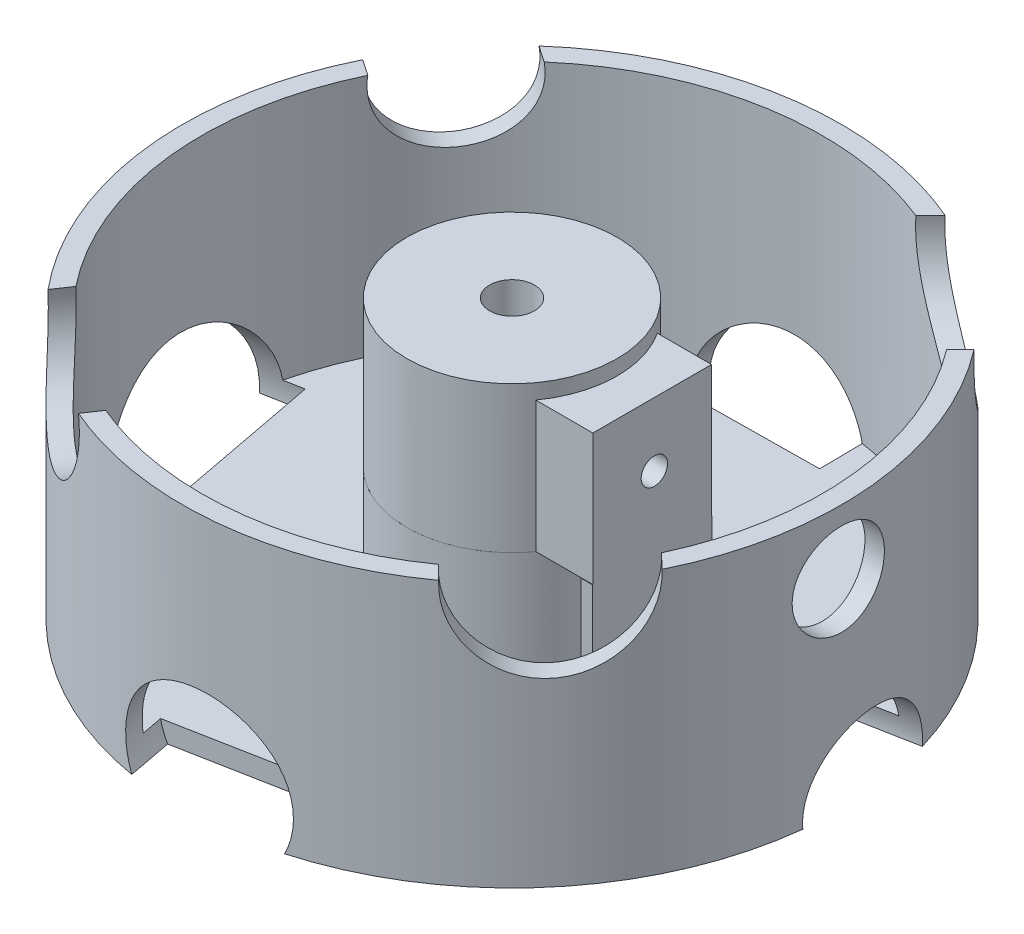
from build123d import *

# Parameters (mm, degrees)
SKETCH1_R                      = 15.958
SHAFTHOLDERNEARMOTOR_DEPTH     = 22.19
SKETCH2_R                      = 3.4
CUT_EXTRUDE1_DEPTH             = 14.35
SKETCH5_W                      = 1.550685087
SKETCH5_H                      = 7.184215806
BOSS_EXTRUDE2_DEPTH            = 13.55
SKETCH7_W                      = 18.003976239
SKETCH7_H                      = 19.909960041
BOSS_EXTRUDE3_DEPTH            = 19
SKETCH6_R                      = 2
CUT_EXTRUDE2_DEPTH             = 1
CUT_EXTRUDE2_DEPTH_BACK        = 19
SKETCH9_W                      = 7.520011657
SKETCH9_H                      = 9.493348351
NUTOPENING_DEPTH               = 30
SKETCH10_R                     = 50
BOSS_EXTRUDE4_DEPTH            = 20
SKETCH12_R                     = 47.082764373
SKETCH12_R_2                   = 15.95790089
CUTTOREMVEEXCESSMATERIAL_DEPTH = 17
SKETCH13_R                     = 50
SKETCH13_R_2                   = 47.082764373
BOSS_EXTRUDE5_DEPTH            = 20
CUT_EXTRUDE6_DEPTH             = 7.520012
SKETCH16_R                     = 7
CUT_EXTRUDE7_DEPTH             = 40
SKETCH19_R                     = 12
CUT_EXTRUDE8_DEPTH             = 10
SKETCH20_R                     = 12
CUT_EXTRUDE9_DEPTH             = 10
SKETCH22_R                     = 12.553525499
CUT_EXTRUDE10_DEPTH            = 10
SKETCH21_R                     = 10
CUT_EXTRUDE11_DEPTH            = 10
SKETCH23_R                     = 11.965333231
CUT_EXTRUDE12_DEPTH            = 10
SKETCH25_R                     = 9.629681042
CUT_EXTRUDE13_DEPTH            = 10
SKETCH26_R                     = 15.012411299
CUT_EXTRUDE14_DEPTH            = 10
SKETCH27_R                     = 11.854712092
CUT_EXTRUDE15_DEPTH            = 10
SKETCH28_W                     = 1.716796753
SKETCH28_H                     = 18.172415452
BOSS_EXTRUDE6_DEPTH            = 17


with BuildPart() as part:
    # Sketch1 → ShaftHolderNearMotor (new body)
    with BuildSketch(Plane(origin=(0, 0, 0), x_dir=(1, 0, 0), z_dir=(0, 1, 0))):
        Circle(SKETCH1_R)
    extrude(amount=SHAFTHOLDERNEARMOTOR_DEPTH)

    # Sketch2 → Cut-Extrude1 (cut)
    with BuildSketch(Plane(origin=(0, 22.19, 0), x_dir=(1, 0, 0), z_dir=(0, 1, 0))):
        Circle(SKETCH2_R)
    extrude(amount=-CUT_EXTRUDE1_DEPTH, mode=Mode.SUBTRACT)

    # Sketch5 → Boss-Extrude2 (add)
    with BuildSketch(Plane(origin=(0, 19.65, 0), x_dir=(1, 0, 0), z_dir=(0, 1, 0))):
        with Locations((3.375342544, 0.020519704)):
            Rectangle(SKETCH5_W, SKETCH5_H)
    extrude(amount=-BOSS_EXTRUDE2_DEPTH)

    # Sketch7 → Boss-Extrude3 (add)
    with BuildSketch(Plane.ZY.offset(-2.6)):
        with Locations((0.33027221, 9.954980021)):
            Rectangle(SKETCH7_W, SKETCH7_H)
    extrude(amount=-BOSS_EXTRUDE3_DEPTH)

    # Sketch6 → Cut-Extrude2 (cut, two sides)
    with BuildSketch(Plane.ZY.offset(-2.6)) as cut_extrude2_sk:
        with Locations((0, 10.236925537)):
            Circle(SKETCH6_R)
    extrude(amount=CUT_EXTRUDE2_DEPTH, mode=Mode.SUBTRACT)
    extrude(cut_extrude2_sk.sketch, amount=-CUT_EXTRUDE2_DEPTH_BACK, mode=Mode.SUBTRACT)

    # Sketch9 → NutOpening (cut)
    with BuildSketch(Plane.XY):
        with Locations((8.412034495, 10.235526917)):
            Rectangle(SKETCH9_W, SKETCH9_H)
    extrude(amount=-NUTOPENING_DEPTH, mode=Mode.SUBTRACT)

    # Sketch10 → Boss-Extrude4 (add)
    with BuildSketch(Plane.XZ):
        Circle(SKETCH10_R)
    extrude(amount=BOSS_EXTRUDE4_DEPTH)

    # Sketch12 → CutToRemveExcessMaterial (cut)
    with BuildSketch(Plane(origin=(0, 0, 0), x_dir=(1, 0, 0), z_dir=(0, 1, 0))):
        Circle(SKETCH12_R)
        Circle(SKETCH12_R_2, mode=Mode.SUBTRACT)
    extrude(amount=-CUTTOREMVEEXCESSMATERIAL_DEPTH, mode=Mode.SUBTRACT)

    # Sketch13 → Boss-Extrude5 (add)
    with BuildSketch(Plane(origin=(0, 0, 0), x_dir=(1, 0, 0), z_dir=(0, 1, 0))):
        Circle(SKETCH13_R)
        Circle(SKETCH13_R_2, mode=Mode.SUBTRACT)
    extrude(amount=BOSS_EXTRUDE5_DEPTH)

    # Sketch14 → Cut-Extrude6 (cut)
    with BuildSketch(Plane.ZY.offset(-12.172040323)):
        Polygon((-5.95412426, 10.236925537), (-2.97706213, 5.08050267), (2.97706213, 5.08050267), (5.95412426, 10.236925537), (2.97706213, 15.393348403), (-2.97706213, 15.393348403), align=None)
    extrude(amount=CUT_EXTRUDE6_DEPTH, mode=Mode.SUBTRACT)

    # Sketch16 → Cut-Extrude7 (cut)
    with BuildSketch(Plane(origin=(21.6, 0, 0), x_dir=(0, 0, -1), z_dir=(1, 0, 0))):
        with Locations((0, 10.236925537)):
            Circle(SKETCH16_R)
    extrude(amount=CUT_EXTRUDE7_DEPTH, mode=Mode.SUBTRACT)

    # Sketch19 → Cut-Extrude8 (cut)
    with BuildSketch(Plane(origin=(9.351145186, 0, 49.117777675), x_dir=(0.982355553, 0, -0.187022904), z_dir=(0.187022904, 0, 0.982355553))):
        with Locations((-6.553798813, -15.044376388)):
            Circle(SKETCH19_R)
    extrude(amount=-CUT_EXTRUDE8_DEPTH, mode=Mode.SUBTRACT)

    # Sketch20 → Cut-Extrude9 (cut)
    with BuildSketch(Plane(origin=(35.756785301, 0, 34.949281894), x_dir=(0.698985638, 0, -0.715135706), z_dir=(0.715135706, 0, 0.698985638))):
        with Locations((3.558365894, 19.429208609)):
            Circle(SKETCH20_R)
    extrude(amount=-CUT_EXTRUDE9_DEPTH, mode=Mode.SUBTRACT)

    # Sketch22 → Cut-Extrude10 (cut)
    with BuildSketch(Plane(origin=(34.949281894, 0, -35.756785301), x_dir=(-0.715135706, 0, -0.698985638), z_dir=(0.698985638, 0, -0.715135706))):
        with Locations((5.427738333, 18.490794011)):
            Circle(SKETCH22_R)
    extrude(amount=-CUT_EXTRUDE10_DEPTH, mode=Mode.SUBTRACT)

    # Sketch21 → Cut-Extrude11 (cut)
    with BuildSketch(Plane(origin=(49.117777675, 0, -9.351145186), x_dir=(-0.187022904, 0, -0.982355553), z_dir=(0.982355553, 0, -0.187022904))):
        with Locations((-4.791175632, -19.221882877)):
            Circle(SKETCH21_R)
    extrude(amount=-CUT_EXTRUDE11_DEPTH, mode=Mode.SUBTRACT)

    # Sketch23 → Cut-Extrude12 (cut)
    with BuildSketch(Plane(origin=(-0.570991135, 0, -49.996739585), x_dir=(-0.999934792, 0, 0.011419823), z_dir=(-0.011419823, 0, -0.999934792))):
        with Locations((4.525183767, -20.017770037)):
            Circle(SKETCH23_R)
    extrude(amount=-CUT_EXTRUDE12_DEPTH, mode=Mode.SUBTRACT)

    # Sketch25 → Cut-Extrude13 (cut)
    with BuildSketch(Plane(origin=(-41.343771844, 0, -28.119255498), x_dir=(-0.56238511, 0, 0.826875437), z_dir=(-0.826875437, 0, -0.56238511))):
        with Locations((-2.649823638, 18.643158668)):
            Circle(SKETCH25_R)
    extrude(amount=-CUT_EXTRUDE13_DEPTH, mode=Mode.SUBTRACT)

    # Sketch26 → Cut-Extrude14 (cut)
    with BuildSketch(Plane(origin=(-49.117777675, 0, 9.351145186), x_dir=(0.187022904, 0, 0.982355553), z_dir=(-0.982355553, 0, 0.187022904))):
        with Locations((-4.497650602, -19.126376963)):
            Circle(SKETCH26_R)
    extrude(amount=-CUT_EXTRUDE14_DEPTH, mode=Mode.SUBTRACT)

    # Sketch27 → Cut-Extrude15 (cut)
    with BuildSketch(Plane(origin=(-28.119255498, 0, 41.343771844), x_dir=(0.826875437, 0, 0.56238511), z_dir=(-0.56238511, 0, 0.826875437))):
        with Locations((-2.287517393, 17.62218093)):
            Circle(SKETCH27_R)
    extrude(amount=-CUT_EXTRUDE15_DEPTH, mode=Mode.SUBTRACT)

    # Sketch28 → Boss-Extrude6 (add)
    with BuildSketch(Plane.XZ):
        with Locations((20.741601624, 0.317955018)):
            Rectangle(SKETCH28_W, SKETCH28_H)
    extrude(amount=BOSS_EXTRUDE6_DEPTH)


solid = part.part
